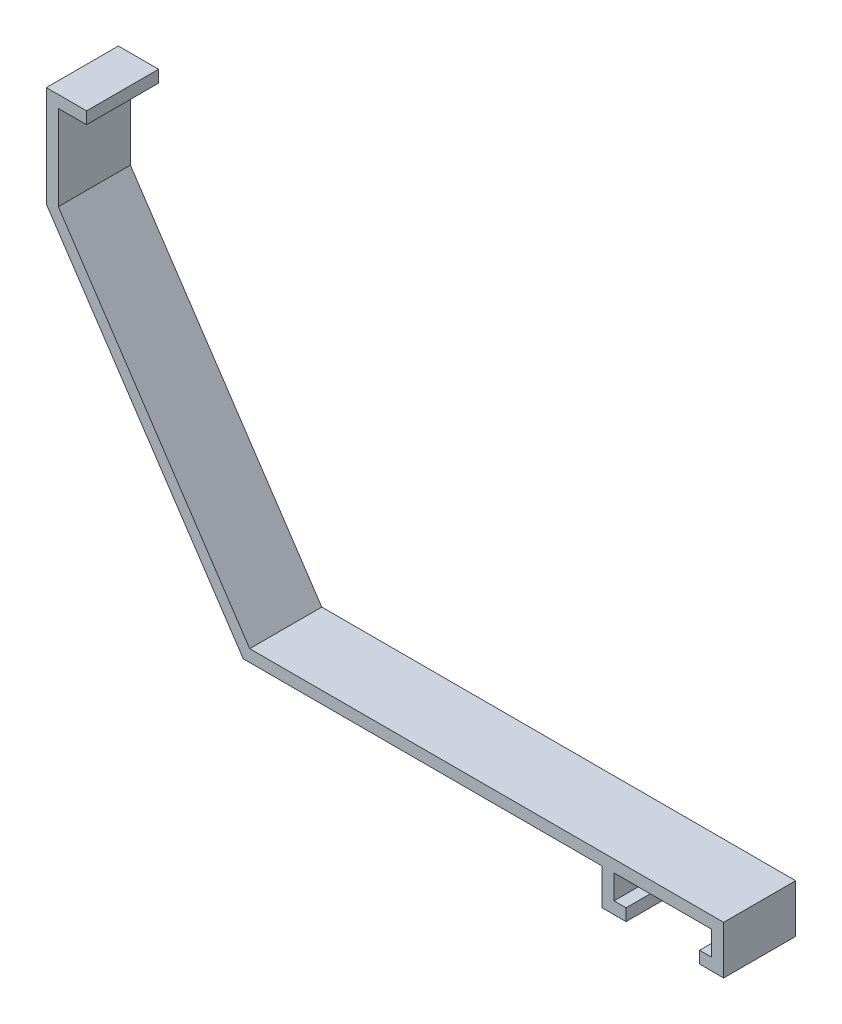
from build123d import *

# Parameters (mm, degrees)
BOSS_EXTRUDE1_DEPTH = 9.525


with BuildPart() as part:
    # Sketch1 → Boss-Extrude1 (new body)
    with BuildSketch(Plane.XY):
        Polygon((0, 0), (-5.3213, 0), (-5.3213, -13.319159726), (20.715282574, -52.374133315), (68.140282574, -52.374133315), (68.140282574, -57.161633315), (71.315282574, -57.161633315), (71.315282574, -55.574133315), (69.727782574, -55.574133315), (69.727782574, -52.374133315), (82.627782574, -52.374133315), (82.627782574, -55.574133315), (81.040282574, -55.574133315), (81.040282574, -57.161633315), (84.215282574, -57.161633315), (84.215282574, -50.786633315), (21.564887994, -50.786633315), (-3.7338, -12.838504422), (-3.7338, -1.5875), (0, -1.5875), align=None)
    extrude(amount=BOSS_EXTRUDE1_DEPTH)


solid = part.part
